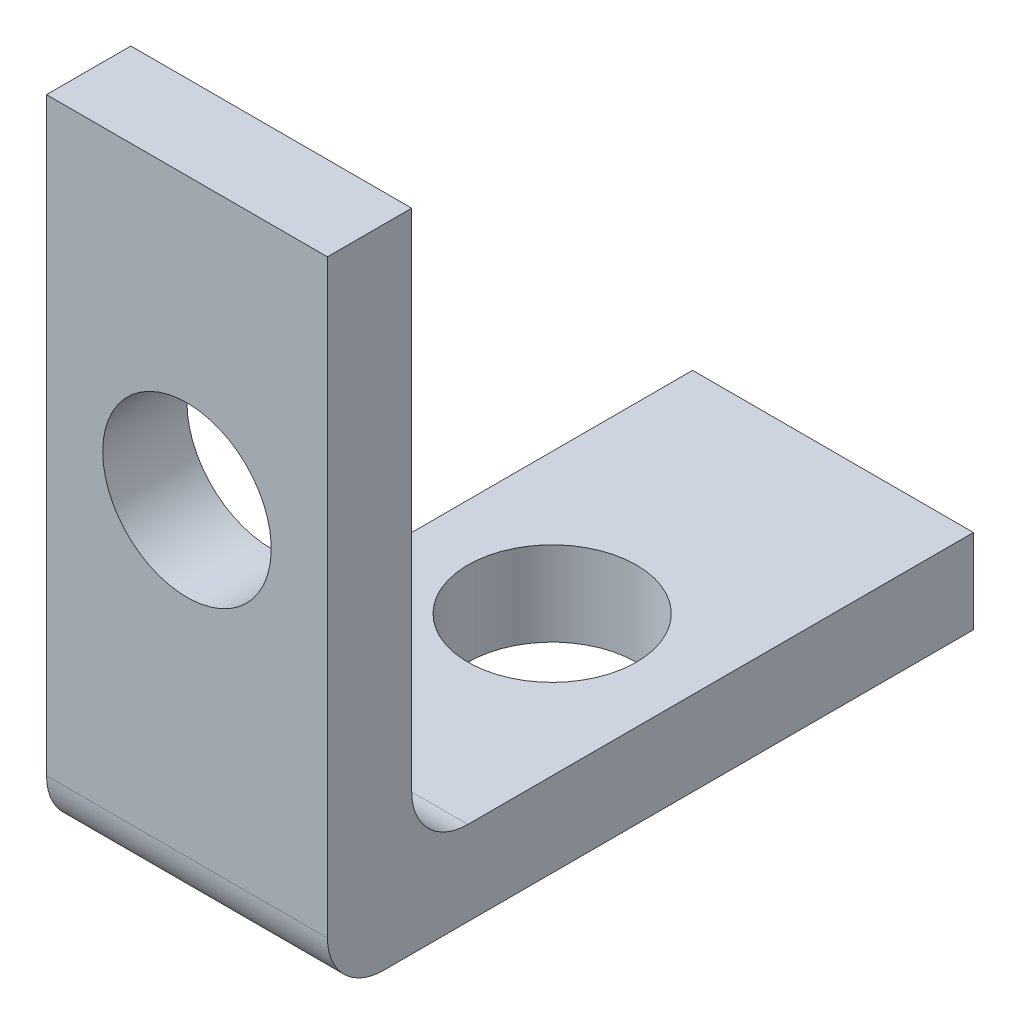
from build123d import *

# Parameters (mm, degrees)
SKETCH1_W               = 5
SKETCH1_H               = 10
BOSS_EXTRUDE1_DEPTH     = 1.5
SKETCH2_W               = 5
SKETCH2_H               = 11.5
BOSS_EXTRUDE2_DEPTH     = 1.5
CUT_EXTRUDE1_DEPTH      = 1.5
CUT_EXTRUDE1_DEPTH_BACK = 10
SKETCH3_R               = 1.5
CUT_EXTRUDE2_DEPTH      = 10
CUT_EXTRUDE2_DEPTH_BACK = 10
SKETCH4_R               = 1.5
FILLET1_R               = 1
FILLET2_R               = 1


with BuildPart() as part:
    # Sketch1 → Boss-Extrude1 (new body)
    with BuildSketch(Plane(origin=(0, 0, 0), x_dir=(1, 0, 0), z_dir=(0, 1, 0))):
        with Locations((2.5, 5)):
            Rectangle(SKETCH1_W, SKETCH1_H)
    extrude(amount=BOSS_EXTRUDE1_DEPTH)

    # Sketch2 → Boss-Extrude2 (add)
    with BuildSketch(Plane.XY):
        with Locations((2.5, 5.75)):
            Rectangle(SKETCH2_W, SKETCH2_H)
    extrude(amount=BOSS_EXTRUDE2_DEPTH)

    # Sketch3 → Cut-Extrude1 (cut, two sides: drawn at the far end of the back side and taken through both)
    with BuildSketch(Plane(origin=(0, 1.5, 0), x_dir=(1, 0, 0), z_dir=(0, 1, 0)).offset(-CUT_EXTRUDE1_DEPTH_BACK)):
        with Locations((2.5, 5)):
            Circle(SKETCH3_R)
    extrude(amount=CUT_EXTRUDE1_DEPTH + CUT_EXTRUDE1_DEPTH_BACK, mode=Mode.SUBTRACT)

    # Sketch4 → Cut-Extrude2 (cut, two sides: drawn at the far end of the back side and taken through both)
    with BuildSketch(Plane(origin=(0, 0, 0), x_dir=(-1, 0, 0), z_dir=(0, 0, -1)).offset(-CUT_EXTRUDE2_DEPTH_BACK)):
        with Locations((-2.5, 6.5)):
            Circle(SKETCH4_R)
    extrude(amount=CUT_EXTRUDE2_DEPTH + CUT_EXTRUDE2_DEPTH_BACK, mode=Mode.SUBTRACT)

    # Fillet1
    fillet1_edges = [part.edges().sort_by_distance(p)[0] for p in [
        (2.5, 1.5, 0),
    ]]
    fillet(fillet1_edges, radius=FILLET1_R)

    # Fillet2
    fillet2_edges = [part.edges().sort_by_distance(p)[0] for p in [
        (2.5, 0, 1.5),
    ]]
    fillet(fillet2_edges, radius=FILLET2_R)


solid = part.part
